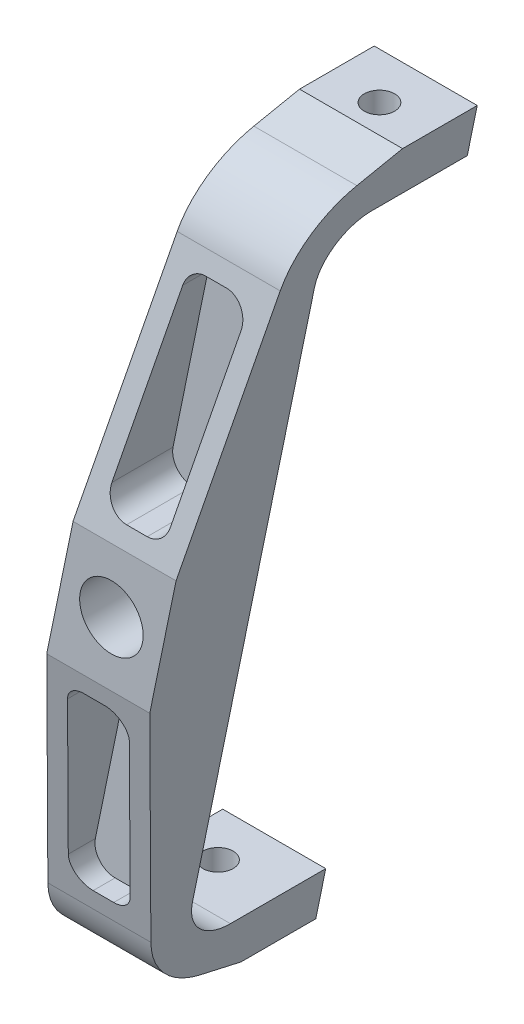
from build123d import *
from OCP.BRepFilletAPI import BRepFilletAPI_MakeChamfer

# Parameters (mm, degrees)
SKETCH1_R           = 10
BOSS_EXTRUDE1_DEPTH = 28.5
BOSS_EXTRUDE2_DEPTH = 45
CUT_EXTRUDE1_DEPTH  = 30
CIRPATTERN1_COUNT   = 2
CHAMFER1_SIZE       = 50
CHAMFER1_SIZE2      = 13.397459622
FILLET3_R           = 15
CHAMFER2_SIZE       = 90
CHAMFER2_SIZE2      = 13.607292824
CUT_EXTRUDE2_DEPTH  = 138.877715566
CUT_EXTRUDE4_DEPTH  = 22.15
FILLET6_R           = 6.35


with BuildPart() as part:
    # Sketch1 → Boss-Extrude1 (new body)
    with BuildSketch(Plane.XY):
        Polygon((-9.192766332, -123.5075), (41.607233668, 123.5075), (9.192766332, 123.5075), (-41.607233668, -123.5075), align=None)
        with Locations(Location((0, 0, 0), (0, 0, 180))):
            Circle(SKETCH1_R, mode=Mode.SUBTRACT)
    extrude(amount=BOSS_EXTRUDE1_DEPTH)

    # Sketch2 → Boss-Extrude2 (add)
    with BuildSketch(Plane(origin=(0, 0, 0), x_dir=(-1, 0, 0), z_dir=(0, 0, -1))):
        Polygon((-41.607233668, 123.5075), (-38.473043437, 108.2675), (-6.0585761, 108.2675), (-9.192766332, 123.5075), align=None)
        Polygon((38.473043437, -108.2675), (6.0585761, -108.2675), (9.192766332, -123.5075), (41.607233668, -123.5075), align=None)
    extrude(amount=BOSS_EXTRUDE2_DEPTH)

    # Sketch4 → Cut-Extrude1 (cut)
    with BuildSketch(Plane(origin=(0, 123.5075, 0), x_dir=(1, 0, 0), z_dir=(0, 1, 0))):
        with BuildLine():
            ThreePointArc((20.6375, 30.433032299), (22.032403955, 27.065436254), (25.4, 25.670532299))
            Line((25.4, 25.670532299), (25.4, 30.433032299))
            Line((25.4, 30.433032299), (20.6375, 30.433032299))
        make_face()
        with BuildLine():
            Line((25.4, 30.433032299), (25.4, 25.670532299))
            ThreePointArc((25.4, 25.670532299), (28.767596045, 27.065436254), (30.1625, 30.433032299))
            Line((30.1625, 30.433032299), (25.4, 30.433032299))
        make_face()
        with BuildLine():
            Line((20.6375, 30.433032299), (25.4, 30.433032299))
            Line((25.4, 30.433032299), (25.4, 35.195532299))
            ThreePointArc((25.4, 35.195532299), (22.032403955, 33.800628344), (20.6375, 30.433032299))
        make_face()
        with BuildLine():
            Line((25.4, 35.195532299), (25.4, 30.433032299))
            Line((25.4, 30.433032299), (30.1625, 30.433032299))
            ThreePointArc((30.1625, 30.433032299), (28.767596045, 33.800628344), (25.4, 35.195532299))
        make_face()
    cut_extrude1 = extrude(amount=-CUT_EXTRUDE1_DEPTH, mode=Mode.SUBTRACT)

    # CirPattern1: Cut-Extrude1 ×2 about axis
    cirpattern1_axis = Axis((0, 0, 28.5), (0, 0, -1))
    for i in range(1, CIRPATTERN1_COUNT):
        add(cut_extrude1.rotate(cirpattern1_axis, i * 360 / CIRPATTERN1_COUNT), mode=Mode.SUBTRACT)

    # Chamfer1: one chamfer whose edges measure the first distance from different faces: ONE call of the kernel's chamfer builder (chamfer() names one face for all edges)
    chamfer1_edges_1 = [part.edges().sort_by_distance(p)[0] for p in [
        (-25.4, -123.5075, 28.5),
    ]]
    chamfer1_side_1 = [part.faces().sort_by_distance(p)[0] for p in [
        (-25.4, -123.5075, -7.566085514),
    ]]
    chamfer1_edges_2 = [part.edges().sort_by_distance(p)[0] for p in [
        (25.4, 123.5075, 28.5),
    ]]
    chamfer1_side_2 = [part.faces().sort_by_distance(p)[0] for p in [
        (25.4, 123.5075, -7.566085514),
    ]]
    chamfer1 = BRepFilletAPI_MakeChamfer(part.part.solid().wrapped)
    for e in chamfer1_edges_1:
        chamfer1.Add(CHAMFER1_SIZE, CHAMFER1_SIZE2, e.wrapped, chamfer1_side_1[0].wrapped)  # the first distance lies on this face
    for e in chamfer1_edges_2:
        chamfer1.Add(CHAMFER1_SIZE, CHAMFER1_SIZE2, e.wrapped, chamfer1_side_2[0].wrapped)  # the first distance lies on this face
    add(Compound.cast(chamfer1.Shape()), mode=Mode.REPLACE)

    # Fillet3
    fillet3_edges = [part.edges().sort_by_distance(p)[0] for p in [
        (22.265809769, 108.2675, 0),
        (-22.265809769, -108.2675, 0),
    ]]
    fillet(fillet3_edges, radius=FILLET3_R)

    # Chamfer2
    chamfer2_edges = [part.edges().sort_by_distance(p)[0] for p in [
        (-22.644738381, -110.110040378, 28.5),
        (22.644738381, 110.110040378, 28.5),
    ]]
    chamfer2_side = [part.faces().sort_by_distance(p)[0] for p in [
        (13.919836124, 0.470415947, 28.5),
    ]]
    chamfer(chamfer2_edges, length=CHAMFER2_SIZE, length2=CHAMFER2_SIZE2, reference=chamfer2_side[0])

    # Sketch10 → Cut-Extrude2 (cut, symmetric)
    with BuildSketch(Plane(origin=(0, 0, 0), x_dir=(0, 0, -1), z_dir=(1, 0, 0))):
        with BuildLine():
            Line((-28.5, 20.110040378), (-11.939027322, 98.927851264))
            ThreePointArc((-11.939027322, 98.927851264), (-4.989688501, 112.1926981), (7.875417438, 119.856804105))
            Line((7.875417438, 119.856804105), (-24.698068362, 128.387749722))
            Line((-24.698068362, 128.387749722), (-33.956814005, 23.522391457))
            Line((-33.956814005, 23.522391457), (-28.5, 20.110040378))
        make_face()
    cut_extrude2 = extrude(amount=CUT_EXTRUDE2_DEPTH, both=True, mode=Mode.SUBTRACT)

    # Mirror1: Cut-Extrude2 across plane
    add(cut_extrude2.mirror(Plane.ZX), mode=Mode.SUBTRACT)

    # Sketch11 → Cut-Extrude4 (cut)
    with BuildSketch(Plane.XY.offset(28.5)):
        Polygon((15.129215341, 26.281205366), (-4.316825144, 26.294041963), (9.314806588, 92.577851264), (28.763486991, 92.577851264), align=None)
        Polygon((-15.165993749, -26.460040378), (4.282686653, -26.460040378), (-9.314806588, -92.577851264), (-28.763486991, -92.577851264), align=None)
    extrude(amount=-CUT_EXTRUDE4_DEPTH, mode=Mode.SUBTRACT)

    # Fillet6
    fillet6_edges = [part.edges().sort_by_distance(p)[0] for p in [
        (15.129215341, 26.281205366, 16.776666244),
        (-4.316825144, 26.294041963, 16.775317649),
        (9.314806588, 92.577851264, 9.811635567),
        (28.763486991, 92.577851264, 9.811635567),
        (-28.763486991, -92.577851264, 9.811635567),
        (-9.314806588, -92.577851264, 9.811635567),
        (4.282686653, -26.460040378, 16.757878094),
        (-15.165993749, -26.460040378, 16.757878094),
    ]]
    fillet(fillet6_edges, radius=FILLET6_R)


solid = part.part
